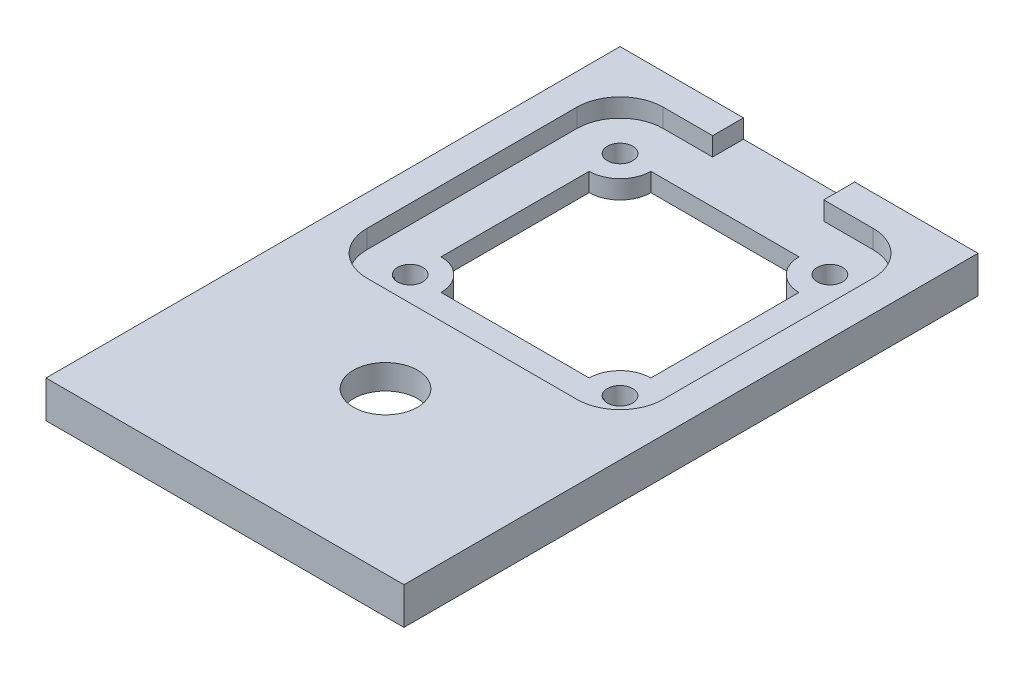
from build123d import *

# Parameters (mm, degrees)
SKETCH3_W           = 29
SKETCH3_H           = 46.502559765
SKETCH3_R           = 2.6
BOSS_EXTRUDE1_DEPTH = 3
SKETCH4_W           = 20.4
SKETCH4_H           = 20.4
CUT_EXTRUDE1_DEPTH  = 1
CUT_EXTRUDE2_DEPTH  = 1.5
SKETCH6_R           = 1.025
CUT_EXTRUDE3_DEPTH  = 1.5
CUT_EXTRUDE4_DEPTH  = 1.5


with BuildPart() as part:
    # Sketch3 → Boss-Extrude1 (new body)
    with BuildSketch(Plane(origin=(0, 0, 0), x_dir=(1, 0, 0), z_dir=(0, 1, 0))):
        with Locations((-0.002492114, -8.748720117)):
            Rectangle(SKETCH3_W, SKETCH3_H)
        with Locations((0, -19)):
            Circle(SKETCH3_R, mode=Mode.SUBTRACT)
    extrude(amount=BOSS_EXTRUDE1_DEPTH)

    # Sketch4 → Cut-Extrude1 (cut)
    with BuildSketch(Plane.XZ):
        with Locations((0, 19)):
            Rectangle(SKETCH4_W, SKETCH4_H)
    extrude(amount=-CUT_EXTRUDE1_DEPTH, mode=Mode.SUBTRACT)

    # Sketch5 → Cut-Extrude2 (cut)
    with BuildSketch(Plane(origin=(0, 3, 0), x_dir=(1, 0, 0), z_dir=(0, 1, 0))):
        with BuildLine():
            Line((-12.00249203, 8.502556434), (-12.00249175, -8.502983271))
            ThreePointArc((-12.00249175, -8.502983271), (-10.973497147, -10.976182335), (-8.497093239, -11.997440002))
            Line((-8.497093239, -11.997440002), (8.497508549, -11.997440458))
            ThreePointArc((8.497508549, -11.997440458), (10.972380637, -10.972314999), (11.99750783, -8.497443607))
            Line((11.99750783, -8.497443607), (11.997507522, 8.497016765))
            ThreePointArc((11.997507522, 8.497016765), (10.976250085, 10.973564476), (8.502907209, 12.002559308))
            Line((8.502907209, 12.002559308), (4.502491803, 12.00255968))
            Line((4.502491803, 12.00255968), (4.502491803, 14.502559765))
            Line((4.502491803, 14.502559765), (-4.502491803, 14.502559765))
            Line((-4.502491803, 14.502559765), (-4.502491803, 12.002559739))
            Line((-4.502491803, 12.002559739), (-8.502491889, 12.002559765))
            ThreePointArc((-8.502491889, 12.002559765), (-10.977366841, 10.977432329), (-12.00249203, 8.502556434))
        make_face()
    extrude(amount=-CUT_EXTRUDE2_DEPTH, mode=Mode.SUBTRACT)

    # Sketch6 → Cut-Extrude3 (cut)
    with BuildSketch(Plane(origin=(0, 1.5, 0), x_dir=(1, 0, 0), z_dir=(0, 1, 0))):
        with Locations((-8.502491891, 8.502559653)):
            Circle(SKETCH6_R)
        with Locations((8.497508109, 8.502559653)):
            Circle(SKETCH6_R)
        with Locations((8.497507663, -8.497440347)):
            Circle(SKETCH6_R)
        with Locations((-8.502492337, -8.497440347)):
            Circle(SKETCH6_R)
    extrude(amount=-CUT_EXTRUDE3_DEPTH, mode=Mode.SUBTRACT)

    # Sketch7 → Cut-Extrude4 (cut)
    with BuildSketch(Plane(origin=(0, 1.5, 0), x_dir=(1, 0, 0), z_dir=(0, 1, 0))):
        with BuildLine():
            Line((-6.002491891, 8.502559653), (5.997508109, 8.502559653))
            ThreePointArc((5.997508109, 8.502559653), (6.729741157, 6.7347927), (8.497508109, 6.002559653))
            Line((8.497508109, 6.002559653), (8.497508109, -5.997440347))
            ThreePointArc((8.497508109, -5.997440347), (6.729740868, -6.729673236), (5.997507663, -8.497440347))
            Line((5.997507663, -8.497440347), (-6.002492337, -8.497440347))
            ThreePointArc((-6.002492337, -8.497440347), (-6.734725226, -6.729673552), (-8.502491891, -5.997440347))
            Line((-8.502491891, -5.997440347), (-8.502491891, 6.002559653))
            ThreePointArc((-8.502491891, 6.002559653), (-6.734724938, 6.7347927), (-6.002491891, 8.502559653))
        make_face()
    extrude(amount=-CUT_EXTRUDE4_DEPTH, mode=Mode.SUBTRACT)


solid = part.part
